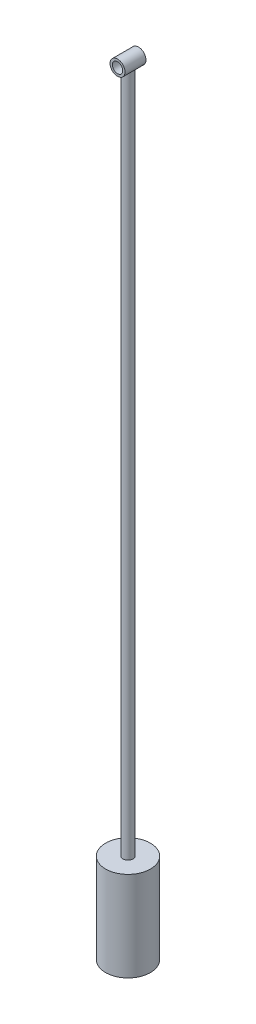
from build123d import *

# Parameters (mm, degrees)
BOSS_EXTRUDE1_START      = -7
SKETCH1_R                = 2.5
SKETCH1_R_2              = 1.733910687
BOSS_EXTRUDE1_DEPTH      = 7
SKETCH2_R                = 1.688720836
BOSS_EXTRUDE2_DEPTH      = 200
BOSS_EXTRUDE2_DEPTH_BACK = 38.25
BOSS_EXTRUDE3_START      = 20
SKETCH3_R                = 7.5
BOSS_EXTRUDE3_DEPTH      = 30


with BuildPart() as part:
    # Sketch1 → Boss-Extrude1 (new body)
    with BuildSketch(Plane.XY.offset(166.922438479).offset(BOSS_EXTRUDE1_START)):
        with Locations((39.892028068, 76.700259913)):
            Circle(SKETCH1_R)
        with Locations((39.892028068, 76.700259913)):
            Circle(SKETCH1_R_2, mode=Mode.SUBTRACT)
    extrude(amount=-BOSS_EXTRUDE1_DEPTH)

    # Sketch2 → Boss-Extrude2 (add, two sides)
    with BuildSketch(Plane.XZ.offset(-36.700259913)) as boss_extrude2_sk:
        with Locations((39.892028068, 156.422438479)):
            Circle(SKETCH2_R)
    extrude(amount=BOSS_EXTRUDE2_DEPTH)
    extrude(boss_extrude2_sk.sketch, amount=-BOSS_EXTRUDE2_DEPTH_BACK)

    # Sketch3 → Boss-Extrude3 (add)
    with BuildSketch(Plane(origin=(0, -163.299740087, 0), x_dir=(-1, 0, 0), z_dir=(0, -1, 0)).offset(BOSS_EXTRUDE3_START)):
        with Locations((-39.892028068, -156.422438479)):
            Circle(SKETCH3_R)
    extrude(amount=-BOSS_EXTRUDE3_DEPTH)


solid = part.part
